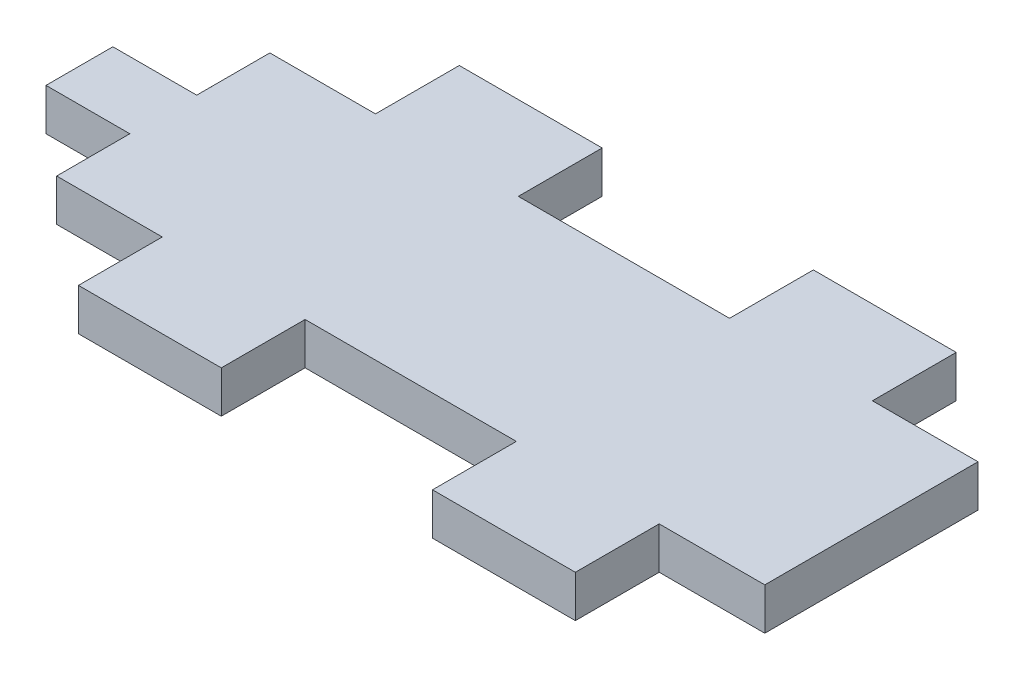
from build123d import *

# Parameters (mm, degrees)
BOSS_EXTRUDE1_DEPTH = 3.175


with BuildPart() as part:
    # Sketch1 → Boss-Extrude1 (new body)
    with BuildSketch(Plane(origin=(0, 0, 0), x_dir=(1, 0, 0), z_dir=(0, 1, 0))):
        Polygon((-33.17059633, -2.5325), (-33.17059633, 2.5325), (-26.82059633, 2.5325), (-26.82059633, 8.075), (-18.82059633, 8.075), (-18.82059633, 14.425), (-8, 14.425), (-8, 8.075), (8, 8.075), (8, 14.425), (18.82059633, 14.425), (18.82059633, 8.075), (26.82059633, 8.075), (26.82059633, -8.075), (18.82059633, -8.075), (18.82059633, -14.425), (8, -14.425), (8, -8.075), (-8, -8.075), (-8, -14.425), (-18.82059633, -14.425), (-18.82059633, -8.075), (-26.82059633, -8.075), (-26.82059633, -2.5325), align=None)
    extrude(amount=BOSS_EXTRUDE1_DEPTH)


solid = part.part
